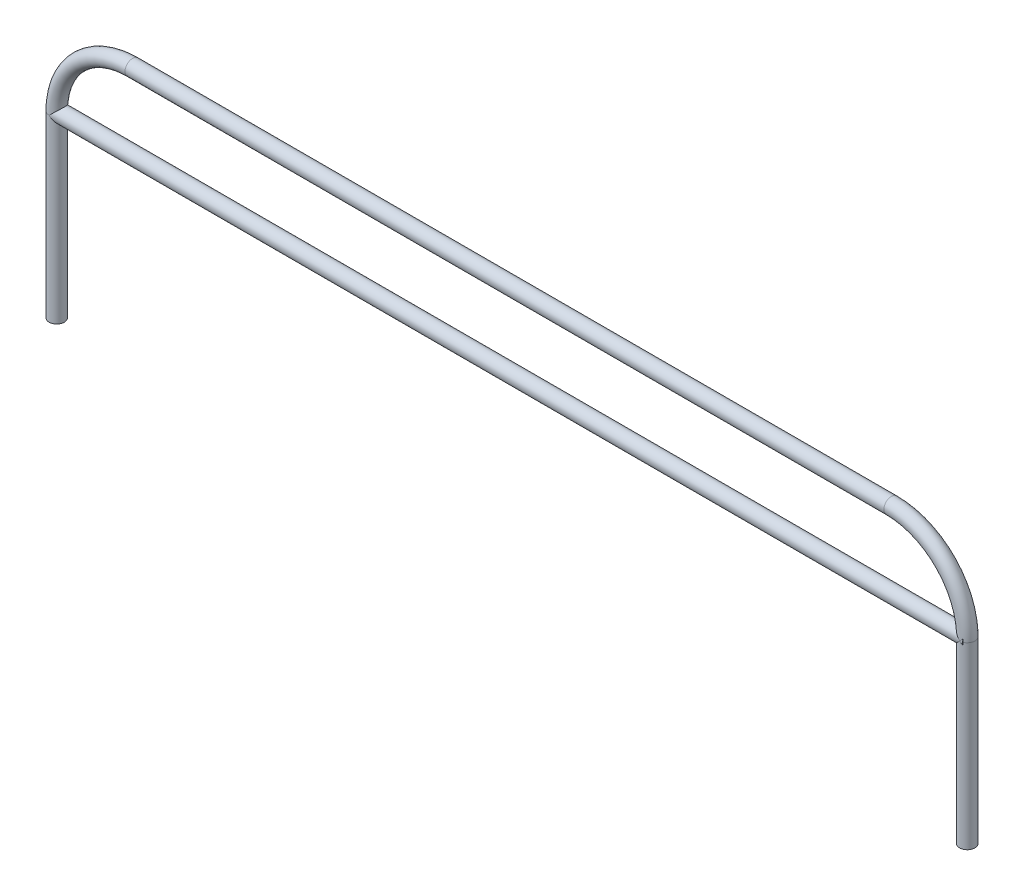
from build123d import *

# Parameters (mm, degrees)
SKETCH2_R           = 12.7
SKETCH4_R           = 12.7
BOSS_EXTRUDE2_DEPTH = 1528.8


with BuildPart() as part:
    # Sweep1: sweep along a path in Sketch1
    with BuildLine(Plane.XY) as sweep1_path:
        Line((0, 0), (0, 300))
        ThreePointArc((0, 300), (37.197438789, 389.802561211), (127, 427))
        Line((127, 427), (1397, 427))
        ThreePointArc((1397, 427), (1486.802561211, 389.802561211), (1524, 300))
        Line((1524, 300), (1524, 0))
    # Sketch2 → Sweep1 (sweep)
    with BuildSketch(Plane(origin=(0, 0, 0), x_dir=(1, 0, 0), z_dir=(0, 1, 0))):
        Circle(SKETCH2_R)
    sweep(path=sweep1_path.line)

    # Sketch4 → Boss-Extrude2 (add)
    with BuildSketch(Plane(origin=(0, 0, 0), x_dir=(0, 0, -1), z_dir=(1, 0, 0))):
        with Locations((0, 300)):
            Circle(SKETCH4_R)
    extrude(amount=BOSS_EXTRUDE2_DEPTH)


solid = part.part
